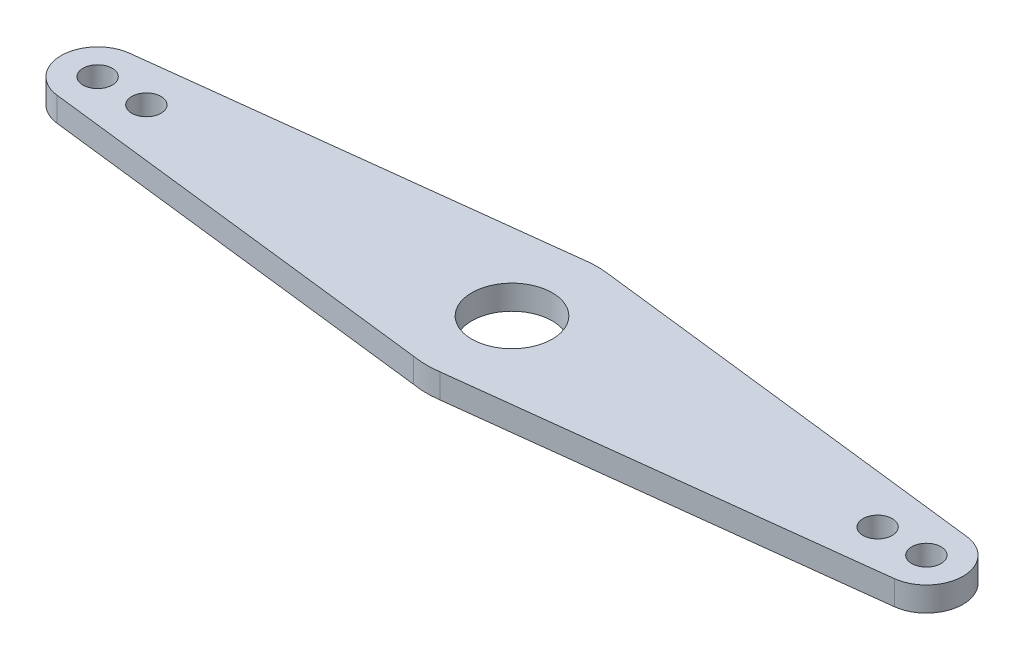
from build123d import *

# Parameters (mm, degrees)
BOSS_EXTRUDE2_DEPTH = 10
SKETCH3_R           = 6
CUT_EXTRUDE1_DEPTH  = 10
SKETCH4_R           = 16.5
CUT_EXTRUDE2_DEPTH  = 10


with BuildPart() as part:
    # Sketch1 → Boss-Extrude2 (new body)
    with BuildSketch(Plane(origin=(0, 0, 0), x_dir=(1, 0, 0), z_dir=(0, 1, 0))):
        with BuildLine():
            Line((-171.764705882, 14.895832073), (-4.117647059, 34.756941504))
            ThreePointArc((-4.117647059, 34.756941504), (0, 35), (4.117647059, 34.756941504))
            Line((4.117647059, 34.756941504), (171.764705882, 14.895832073))
            ThreePointArc((171.764705882, 14.895832073), (184.999999986, -0.000651143), (171.763412633, -14.895985227))
            Line((171.763412633, -14.895985227), (5.118683106, -34.623678072))
            ThreePointArc((5.118683106, -34.623678072), (-0.464934327, -34.996911808), (-6.036666108, -34.475479145))
            Line((-6.036666108, -34.475479145), (-171.759908797, -14.896399599))
            ThreePointArc((-171.759908797, -14.896399599), (-184.999999806, -0.00241527), (-171.764705882, 14.895832073))
        make_face()
    extrude(amount=BOSS_EXTRUDE2_DEPTH)

    # Sketch3 → Cut-Extrude1 (cut)
    with BuildSketch(Plane(origin=(0, 10, 0), x_dir=(1, 0, 0), z_dir=(0, 1, 0))):
        with Locations((170, 0)):
            Circle(SKETCH3_R)
        with Locations((-170, 0)):
            Circle(SKETCH3_R)
        with Locations((-150, 0)):
            Circle(SKETCH3_R)
        with Locations((150, 0)):
            Circle(SKETCH3_R)
    extrude(amount=-CUT_EXTRUDE1_DEPTH, mode=Mode.SUBTRACT)

    # Sketch4 → Cut-Extrude2 (cut)
    with BuildSketch(Plane(origin=(0, 10, 0), x_dir=(1, 0, 0), z_dir=(0, 1, 0))):
        Circle(SKETCH4_R)
    extrude(amount=-CUT_EXTRUDE2_DEPTH, mode=Mode.SUBTRACT)


solid = part.part
